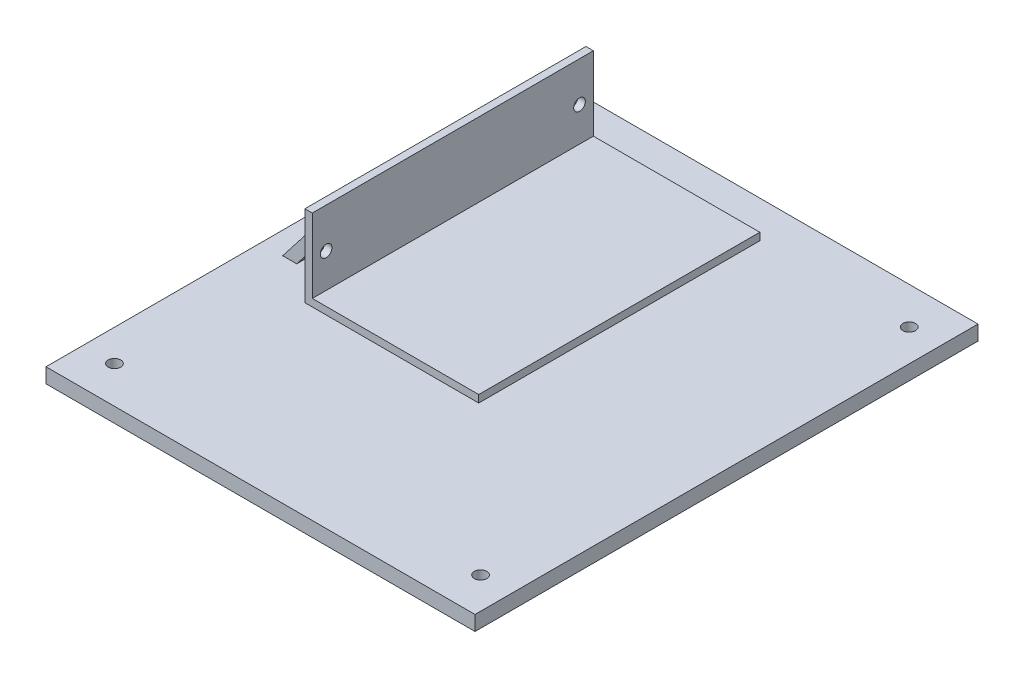
from build123d import *

# Parameters (mm, degrees)
SKETCH1_W           = 147.32
SKETCH1_H           = 5.08
BOSS_EXTRUDE1_DEPTH = 172.72
SKETCH2_R           = 2.159
CUT_EXTRUDE1_DEPTH  = 6.08
SKETCH3_W           = 59.69
SKETCH3_H           = 96.52
BOSS_EXTRUDE2_DEPTH = 2.54
SKETCH4_W           = 2.54
SKETCH4_H           = 96.52
BOSS_EXTRUDE3_DEPTH = 25.4
SKETCH5_W           = 76.2
SKETCH5_H           = 22.86
BOSS_EXTRUDE4_DEPTH = 17.78
CUT_EXTRUDE2_DEPTH  = 100.06
SKETCH7_R           = 2
CUT_EXTRUDE3_DEPTH  = 28.94


with BuildPart() as part:
    # Sketch1 → Boss-Extrude1 (new body)
    with BuildSketch(Plane.XY):
        Rectangle(SKETCH1_W, SKETCH1_H)
    extrude(amount=BOSS_EXTRUDE1_DEPTH)

    # Sketch2 → Cut-Extrude1 (cut, through all)
    with BuildSketch(Plane(origin=(0, 2.54, 0), x_dir=(1, 0, 0), z_dir=(0, 1, 0))):
        with Locations((62.738, -12.7)):
            Circle(SKETCH2_R)
        with Locations((-62.865, -160.02)):
            Circle(SKETCH2_R)
        with Locations((62.865, -160.02)):
            Circle(SKETCH2_R)
        with Locations((-62.738, -12.7)):
            Circle(SKETCH2_R)
    extrude(amount=-CUT_EXTRUDE1_DEPTH, mode=Mode.SUBTRACT)

    # Sketch3 → Boss-Extrude2 (add)
    with BuildSketch(Plane(origin=(0, 2.54, 0), x_dir=(1, 0, 0), z_dir=(0, 1, 0))):
        with Locations((-18.415, -60.96)):
            Rectangle(SKETCH3_W, SKETCH3_H)
    extrude(amount=BOSS_EXTRUDE2_DEPTH)

    # Sketch4 → Boss-Extrude3 (add)
    with BuildSketch(Plane(origin=(0, 5.08, 0), x_dir=(1, 0, 0), z_dir=(0, 1, 0))):
        with Locations((-46.99, -60.96)):
            Rectangle(SKETCH4_W, SKETCH4_H)
    extrude(amount=BOSS_EXTRUDE3_DEPTH)

    # Sketch5 → Boss-Extrude4 (add)
    with BuildSketch(Plane.ZY.offset(48.26)):
        with Locations((60.96, 13.97)):
            Rectangle(SKETCH5_W, SKETCH5_H)
    extrude(amount=BOSS_EXTRUDE4_DEPTH)

    # Sketch6 → Cut-Extrude2 (cut, through all)
    with BuildSketch(Plane.XY.offset(99.06)):
        Polygon((-66.04, 2.54), (-48.26, 25.4), (-66.04, 25.4), align=None)
        Polygon((-61.213257367, 2.54), (-48.26, 19.194188043), (-48.26, 2.54), align=None)
    extrude(amount=-CUT_EXTRUDE2_DEPTH, mode=Mode.SUBTRACT)

    # Sketch7 → Cut-Extrude3 (cut, through all)
    with BuildSketch(Plane(origin=(-45.72, 0, 0), x_dir=(0, 0, -1), z_dir=(1, 0, 0))):
        with Locations((-104.46, 16.83)):
            Circle(SKETCH7_R)
        with Locations((-17.46, 16.83)):
            Circle(SKETCH7_R)
    extrude(amount=-CUT_EXTRUDE3_DEPTH, mode=Mode.SUBTRACT)


solid = part.part
